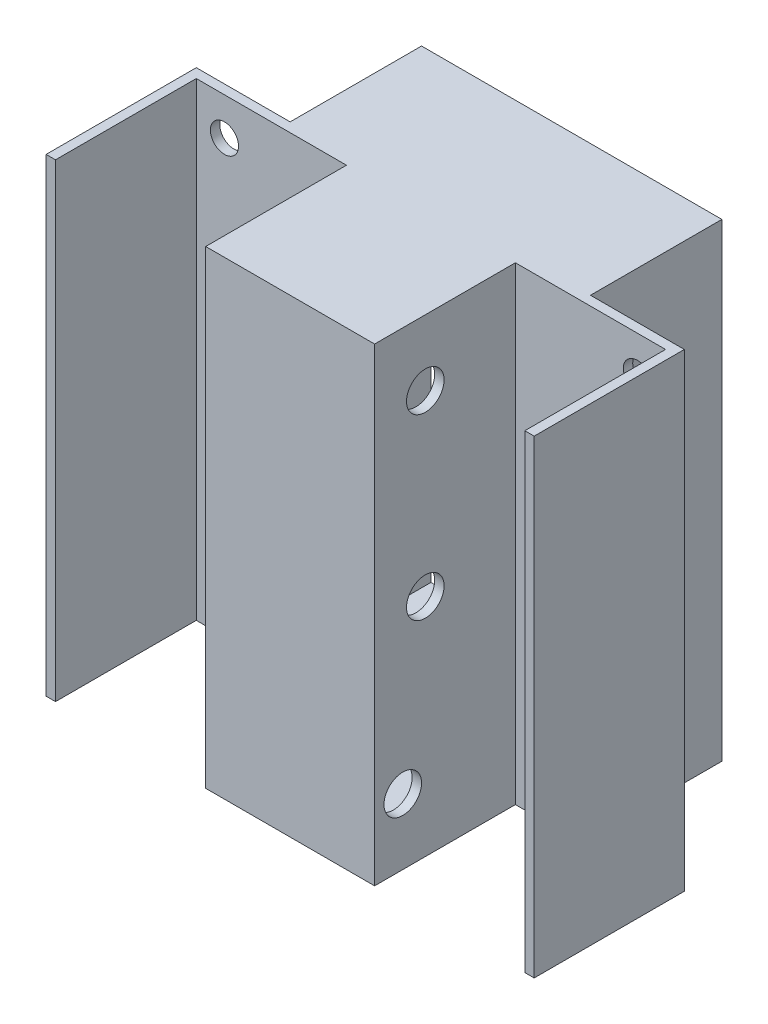
from build123d import *

# Parameters (mm, degrees)
ESQUISSE1_W             = 90
ESQUISSE1_H             = 250
BOSS_EXTRU_1_DEPTH      = 5
ESQUISSE2_W             = 90
ESQUISSE2_H             = 250
ESQUISSE2_W_2           = 80
ESQUISSE2_H_2           = 240
BOSS_EXTRU_2_DEPTH      = 70
BOSS_EXTRU_3_DEPTH      = 5
ESQUISSE4_R             = 10
ENL_V_MAT_EXTRU_2_DEPTH = 171
ESQUISSE5_W             = 80
ESQUISSE5_H             = 250
BOSS_EXTRU_4_DEPTH      = 5
ESQUISSE6_W             = 80
ESQUISSE6_H             = 250
BOSS_EXTRU_5_DEPTH      = 5
ESQUISSE7_W             = 160
ESQUISSE7_H             = 250
ESQUISSE7_W_2           = 150
ESQUISSE7_H_2           = 240
BOSS_EXTRU_6_DEPTH      = 70
ESQUISSE10_R            = 7.5
ENL_V_MAT_EXTRU_3_DEPTH = 50
ESQUISSE12_R            = 20
ENL_V_MAT_EXTRU_4_DEPTH = 10


with BuildPart() as part:
    # Esquisse1 → Boss.-Extru.1 (new body)
    with BuildSketch(Plane.XY):
        with Locations((-45, 125)):
            Rectangle(ESQUISSE1_W, ESQUISSE1_H)
    extrude(amount=BOSS_EXTRU_1_DEPTH)

    # Esquisse2 → Boss.-Extru.2 (add)
    with BuildSketch(Plane(origin=(0, 0, 0), x_dir=(-1, 0, 0), z_dir=(0, 0, -1))):
        with Locations((45, 125)):
            Rectangle(ESQUISSE2_W, ESQUISSE2_H)
        with Locations((45, 125)):
            Rectangle(ESQUISSE2_W_2, ESQUISSE2_H_2, mode=Mode.SUBTRACT)
    extrude(amount=BOSS_EXTRU_2_DEPTH)

    # Esquisse3 → Boss.-Extru.3 (add)
    with BuildSketch(Plane(origin=(0, 0, -70), x_dir=(-1, 0, 0), z_dir=(0, 0, -1))):
        Polygon((6.025463364, 250), (-80, 250), (-80, 0), (-15, 0), (45, 0), (45, 5), (5, 5), (5, 245), (45, 245), (45, 250), align=None)
    boss_extru_3 = extrude(amount=BOSS_EXTRU_3_DEPTH)

    # Symétrie1: Boss.-Extru.3 across plane
    add(boss_extru_3.mirror(Plane(origin=(-45, 245, -75), x_dir=(0, 0, 1), z_dir=(1, 0, 0))))

    # Esquisse4 → Enlèv. mat.-Extru.2 (cut, through all)
    with BuildSketch(Plane.ZY.offset(90)):
        with Locations((-22, 215)):
            Circle(ESQUISSE4_R)
        with Locations((-22, 120)):
            Circle(ESQUISSE4_R)
        with Locations((-10, 35)):
            Circle(ESQUISSE4_R)
    extrude(amount=-ENL_V_MAT_EXTRU_2_DEPTH, mode=Mode.SUBTRACT)

    # Esquisse5 → Boss.-Extru.4 (add)
    with BuildSketch(Plane(origin=(80, 0, 0), x_dir=(0, 0, -1), z_dir=(1, 0, 0))):
        with Locations((35, 125)):
            Rectangle(ESQUISSE5_W, ESQUISSE5_H)
    extrude(amount=BOSS_EXTRU_4_DEPTH)

    # Esquisse6 → Boss.-Extru.5 (add)
    with BuildSketch(Plane.ZY.offset(170)):
        with Locations((-35, 125)):
            Rectangle(ESQUISSE6_W, ESQUISSE6_H)
    extrude(amount=BOSS_EXTRU_5_DEPTH)

    # Esquisse7 → Boss.-Extru.6 (add)
    with BuildSketch(Plane(origin=(0, 0, -75), x_dir=(-1, 0, 0), z_dir=(0, 0, -1))):
        with Locations((45, 125)):
            Rectangle(ESQUISSE7_W, ESQUISSE7_H)
        with Locations((45, 125)):
            Rectangle(ESQUISSE7_W_2, ESQUISSE7_H_2, mode=Mode.SUBTRACT)
    extrude(amount=BOSS_EXTRU_6_DEPTH)

    # Esquisse10 → Enlèv. mat.-Extru.3 (cut)
    with BuildSketch(Plane(origin=(0, 0, -75), x_dir=(-1, 0, 0), z_dir=(0, 0, -1))):
        with Locations((155, 230)):
            Circle(ESQUISSE10_R)
        with Locations((-65, 230)):
            Circle(ESQUISSE10_R)
        with Locations((-65, 160)):
            Circle(ESQUISSE10_R)
        with Locations((155, 160)):
            Circle(ESQUISSE10_R)
        with Locations((-65, 90)):
            Circle(ESQUISSE10_R)
        with Locations((155, 90)):
            Circle(ESQUISSE10_R)
        with Locations((-65, 20)):
            Circle(ESQUISSE10_R)
        with Locations((155, 20)):
            Circle(ESQUISSE10_R)
    extrude(amount=-ENL_V_MAT_EXTRU_3_DEPTH, mode=Mode.SUBTRACT)

    # Esquisse12 → Enlèv. mat.-Extru.4 (cut)
    with BuildSketch(Plane.XZ):
        with Locations((-15, -104.868866133)):
            Circle(ESQUISSE12_R)
        with Locations((-75, -104.868866133)):
            Circle(ESQUISSE12_R)
    extrude(amount=-ENL_V_MAT_EXTRU_4_DEPTH, mode=Mode.SUBTRACT)


solid = part.part
